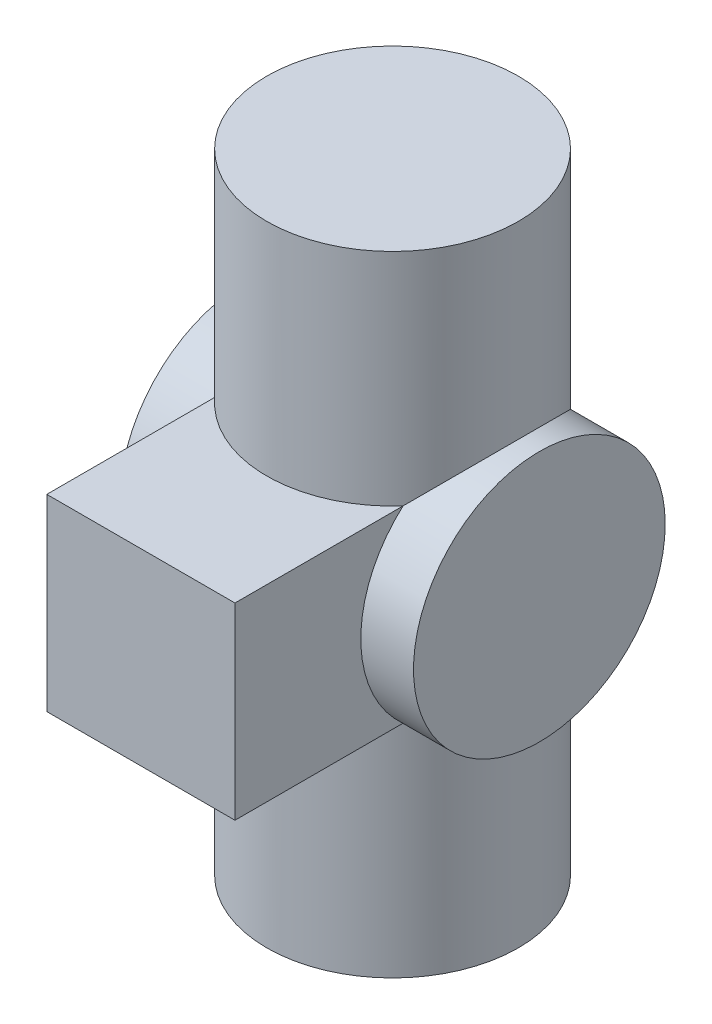
from build123d import *

# Parameters (mm, degrees)
SKETCH1_R           = 30
BOSS_EXTRUDE1_DEPTH = 150
SKETCH3_R           = 30
BOSS_EXTRUDE2_DEPTH = 35
BOSS_EXTRUDE3_DEPTH = 60


with BuildPart() as part:
    # Sketch1 → Boss-Extrude1 (new body)
    with BuildSketch(Plane(origin=(0, 0, 0), x_dir=(1, 0, 0), z_dir=(0, 1, 0))):
        Circle(SKETCH1_R)
    extrude(amount=BOSS_EXTRUDE1_DEPTH)

    # Sketch3 → Boss-Extrude2 (add, symmetric)
    with BuildSketch(Plane(origin=(0, 0, 0), x_dir=(0, 0, -1), z_dir=(1, 0, 0))):
        with Locations((0, 75)):
            Circle(SKETCH3_R)
    extrude(amount=BOSS_EXTRUDE2_DEPTH, both=True)

    # Sketch4 → Boss-Extrude3 (add)
    with BuildSketch(Plane.XY):
        Polygon((0, 97.430213505), (22.430213505, 97.430213505), (22.430213505, 52.569786495), (-22.430213505, 52.569786495), (-22.430213505, 97.430213505), align=None)
    extrude(amount=BOSS_EXTRUDE3_DEPTH)


solid = part.part
